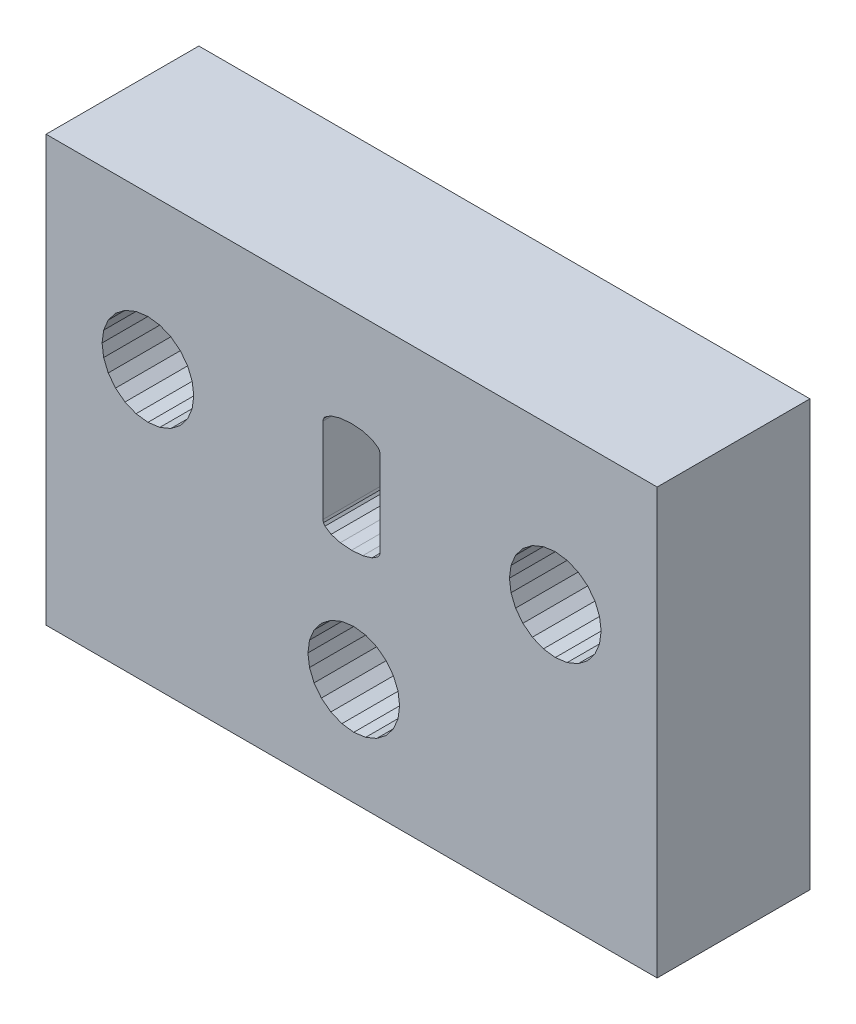
from build123d import *

# Parameters (mm, degrees)
SKETCH1_W           = 23.99999232
SKETCH1_H           = 16.699994656
BOSS_EXTRUDE1_DEPTH = 6


with BuildPart() as part:
    # Sketch1 → Boss-Extrude1 (new body)
    with BuildSketch(Plane.XY):
        with Locations((252.698883135, 126.95689416)):
            Rectangle(SKETCH1_W, SKETCH1_H)
        Polygon((242.898886271, 129.306893408), (242.960219764, 128.841019276), (243.140040467, 128.406893696), (243.426093896, 128.034101609), (243.798885983, 127.74804818), (244.233011562, 127.568227477), (244.698885695, 127.506893984), (245.164759827, 127.568227477), (245.598885407, 127.74804818), (245.971677493, 128.034101609), (246.257730923, 128.406893696), (246.437551626, 128.841019276), (246.498885119, 129.306893408), (246.437551626, 129.77276754), (246.257730923, 130.20689312), (245.971677493, 130.579685207), (245.598885407, 130.865738636), (245.164759827, 131.045559339), (244.698885695, 131.106892832), (244.233011562, 131.045559339), (243.798885983, 130.865738636), (243.426093896, 130.579685207), (243.140040467, 130.20689312), (242.960219764, 129.77276754), align=None, mode=Mode.SUBTRACT)
        Polygon((258.89776474, 129.306893408), (258.959098233, 128.841019276), (259.138918936, 128.406893696), (259.424972365, 128.034101609), (259.797764452, 127.74804818), (260.231890032, 127.568227477), (260.697764164, 127.506893984), (261.163638296, 127.568227477), (261.597763876, 127.74804818), (261.970555963, 128.034101609), (262.256609392, 128.406893696), (262.436430095, 128.841019276), (262.497763588, 129.306893408), (262.436430095, 129.77276754), (262.256609392, 130.20689312), (261.970555963, 130.579685207), (261.597763876, 130.865738636), (261.163638296, 131.045559339), (260.697764164, 131.106892832), (260.231890032, 131.045559339), (259.797764452, 130.865738636), (259.424972365, 130.579685207), (259.138918936, 130.20689312), (258.959098233, 129.77276754), align=None, mode=Mode.SUBTRACT)
        Polygon((251.224802071, 121.906895776), (251.5108555, 121.534103689), (251.883647587, 121.24805026), (252.317773167, 121.068229557), (252.783647299, 121.006896064), (253.249521431, 121.068229557), (253.683647011, 121.24805026), (254.056439098, 121.534103689), (254.342492527, 121.906895776), (254.52231323, 122.341021356), (254.583646723, 122.806895488), (254.52231323, 123.27276962), (254.342492527, 123.7068952), (254.056439098, 124.079687287), (253.683647011, 124.365740716), (253.249521431, 124.545561419), (252.783647299, 124.606894912), (252.317773167, 124.545561419), (251.883647587, 124.365740716), (251.5108555, 124.079687287), (251.224802071, 123.7068952), (251.044981368, 123.27276962), (250.983647875, 122.806895488), (251.044981368, 122.341021356), align=None, mode=Mode.SUBTRACT)
        Polygon((251.571359171, 127.63584663), (251.591456112, 127.539658201), (251.651746937, 127.450883311), (251.892910238, 127.295574145), (252.254274091, 127.190212579), (252.695263515, 127.155092057), (253.13625294, 127.190212579), (253.497616793, 127.295574145), (253.738780093, 127.450883311), (253.799070918, 127.539658201), (253.81916786, 127.63584663), (253.81916786, 130.982264313), (253.799070918, 131.078452742), (253.738780093, 131.167227632), (253.497616793, 131.322536798), (253.13625294, 131.427898364), (252.695263515, 131.463018886), (252.254274091, 131.427898364), (251.892910238, 131.322536798), (251.651746937, 131.167227632), (251.591456112, 131.078452742), (251.571359171, 130.982264313), align=None, mode=Mode.SUBTRACT)
    extrude(amount=BOSS_EXTRUDE1_DEPTH)


solid = part.part
